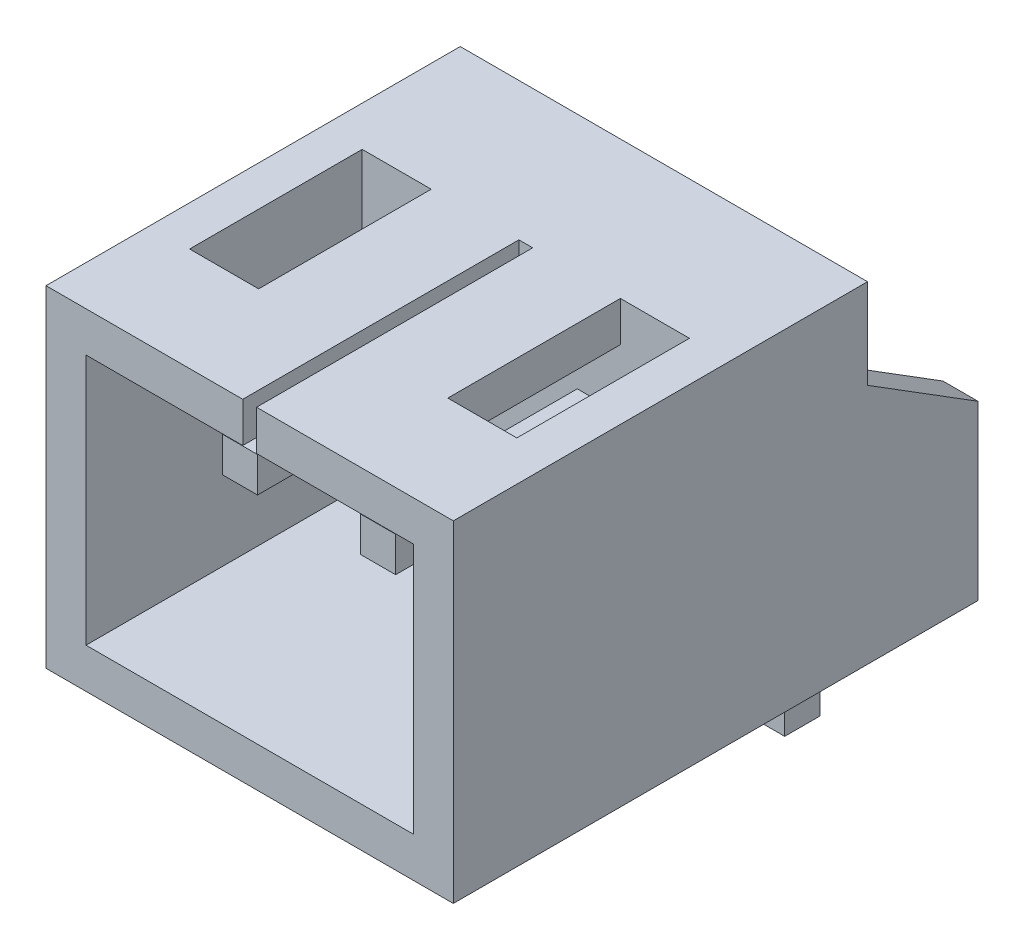
from build123d import *

# Parameters (mm, degrees)
SKETCH4_W                      = 5.9
SKETCH4_H                      = 4.8
BODY_EXTRUDE2_DEPTH            = 6
BODY_SHELL1_T                  = -0.58
BODY_SHELL1_THICKNESS_2_FACE_W = 4.74
BODY_SHELL1_THICKNESS_2_FACE_H = 3.64
BODY_SHELL1_THICKNESS_2_DEPTH  = 1.42
EXTRUDE1_REACH                 = 9.906
SKETCH66_W                     = 0.2
SKETCH66_H                     = 4
SKETCH66_W_2                   = 1
SKETCH66_H_2                   = 2.5
TAB_EXTRUDE4_DEPTH             = 0.508
TAB_EXTRUDE7_DEPTH             = 0.508
SKETCH64_W                     = 0.508
SKETCH64_H                     = 0.508
PINS_LPATTERN_COUNT            = 2
PINS_LPATTERN_PITCH            = 2


with BuildPart() as part:
    # Sketch4 → Body-Extrude2 (new body)
    with BuildSketch(Plane(origin=(6.86422654, -1.863703399, 0), x_dir=(1, 0, 0), z_dir=(0, 0, 1))):
        with Locations((-6.86422654, 1.863703399)):
            Rectangle(SKETCH4_W, SKETCH4_H)
    extrude(amount=BODY_EXTRUDE2_DEPTH)

    # Body-Shell1
    body_shell1_openings = [part.faces().sort_by_distance(p)[0] for p in [
        (0, 0, 6),
    ]]
    offset(amount=BODY_SHELL1_T, openings=body_shell1_openings, kind=Kind.INTERSECTION)

    # Body-Shell1 thickness 2 face (on inner face of the shell) → Body-Shell1 thickness 2 (add)
    with BuildSketch(Plane(origin=(0, 0, 0.58), x_dir=(-1, 0, 0), z_dir=(0, 0, -1))):
        Rectangle(BODY_SHELL1_THICKNESS_2_FACE_W, BODY_SHELL1_THICKNESS_2_FACE_H)
    extrude(amount=-BODY_SHELL1_THICKNESS_2_DEPTH)

    # Sketch66 → Extrude1 (cut, up to next)
    with BuildSketch(Plane(origin=(0, 1.82, 0), x_dir=(1, 0, 0), z_dir=(0, 1, 0)), mode=Mode.PRIVATE) as extrude1_sk1:
        with Locations((0, -4)):
            Rectangle(SKETCH66_W, SKETCH66_H)
    extrude1_tool1 = extrude(extrude1_sk1.sketch, amount=EXTRUDE1_REACH, mode=Mode.PRIVATE) & part.part
    # Sketch66 → Extrude1 (cut, up to next)
    with BuildSketch(Plane(origin=(0, 1.82, 0), x_dir=(1, 0, 0), z_dir=(0, 1, 0)), mode=Mode.PRIVATE) as extrude1_sk2:
        with Locations((-1.87, -3.25)):
            Rectangle(SKETCH66_W_2, SKETCH66_H_2)
    extrude1_tool2 = extrude(extrude1_sk2.sketch, amount=EXTRUDE1_REACH, mode=Mode.PRIVATE) & part.part
    # Sketch66 → Extrude1 (cut, up to next)
    with BuildSketch(Plane(origin=(0, 1.82, 0), x_dir=(1, 0, 0), z_dir=(0, 1, 0)), mode=Mode.PRIVATE) as extrude1_sk3:
        with Locations((1.87, -3.25)):
            Rectangle(SKETCH66_W_2, SKETCH66_H_2)
    extrude1_tool3 = extrude(extrude1_sk3.sketch, amount=EXTRUDE1_REACH, mode=Mode.PRIVATE) & part.part
    add(extrude1_tool1.solids().sort_by_distance((0, 1.82, 4))[0], mode=Mode.SUBTRACT)
    add(extrude1_tool2.solids().sort_by_distance((-1.87, 1.82, 3.25))[0], mode=Mode.SUBTRACT)
    add(extrude1_tool3.solids().sort_by_distance((1.87, 1.82, 3.25))[0], mode=Mode.SUBTRACT)

    # Sketch6 → Tab-Extrude4 (add)
    with BuildSketch(Plane(origin=(2.95, 11.117293973, 0), x_dir=(0, 0, -1), z_dir=(1, 0, 0))):
        Polygon((0, -10.017293973), (1.6, -11.017293973), (1.6, -13.517293973), (0, -13.517293973), align=None)
    extrude(amount=-TAB_EXTRUDE4_DEPTH)

    # Sketch9 → Tab-Extrude7 (add)
    with BuildSketch(Plane(origin=(-2.95, 11.117293973, 0), x_dir=(0, 0, 1), z_dir=(-1, 0, 0))):
        Polygon((0, -13.517293973), (0, -10.017293973), (-1.6, -11.017293973), (-1.6, -13.517293973), align=None)
    extrude(amount=-TAB_EXTRUDE7_DEPTH)


with BuildPart() as body_2:
    # Pins-Sweep: sweep along a path in Sketch65
    with BuildLine(Plane(origin=(0, 0, 0), x_dir=(0, 0, -1), z_dir=(1, 0, 0))) as pins_sweep_path:
        Line((-5.14, 0.7), (-0.25, 0.7))
        ThreePointArc((-0.25, 0.7), (0.457106781, 0.407106781), (0.75, -0.3))
        Line((0.75, -0.3), (0.75, -4.4))
    # Sketch64 → Pins-Sweep (sweep)
    with BuildSketch(Plane(origin=(0, 3.64, 5.14), x_dir=(1, 0, 0), z_dir=(0, 0, -1))):
        with Locations((-1, 2.94)):
            Rectangle(SKETCH64_W, SKETCH64_H)
    pins_sweep = sweep(path=pins_sweep_path.line)


with BuildPart() as part_1:
    add(part.part)

    # Pins-LPattern: Pins-Sweep ×2
    with Locations(*[(i * PINS_LPATTERN_PITCH, 0, 0) for i in range(1, PINS_LPATTERN_COUNT)]):
        add(pins_sweep)


solid = Compound([body_2.part, part_1.part])
